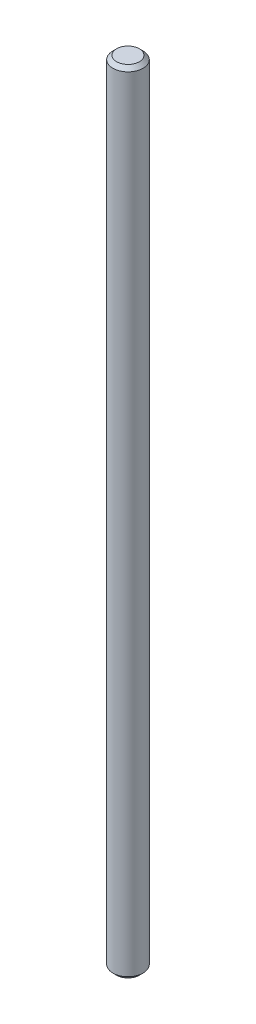
from build123d import *

# Parameters (mm, degrees)
SKETCH1_R           = 2
BOSS_EXTRUDE1_DEPTH = 105
CHAMFER1_SIZE       = 0.5


with BuildPart() as part:
    # Sketch1 → Boss-Extrude1 (new body)
    with BuildSketch(Plane(origin=(0, 0, 0), x_dir=(1, 0, 0), z_dir=(0, 1, 0))):
        Circle(SKETCH1_R)
    extrude(amount=BOSS_EXTRUDE1_DEPTH)

    # Chamfer1
    chamfer1_edges = [part.edges().sort_by_distance(p)[0] for p in [
        (-2, 0, 0),
        (-2, 105, 0),
    ]]
    chamfer(chamfer1_edges, length=CHAMFER1_SIZE)


solid = part.part
